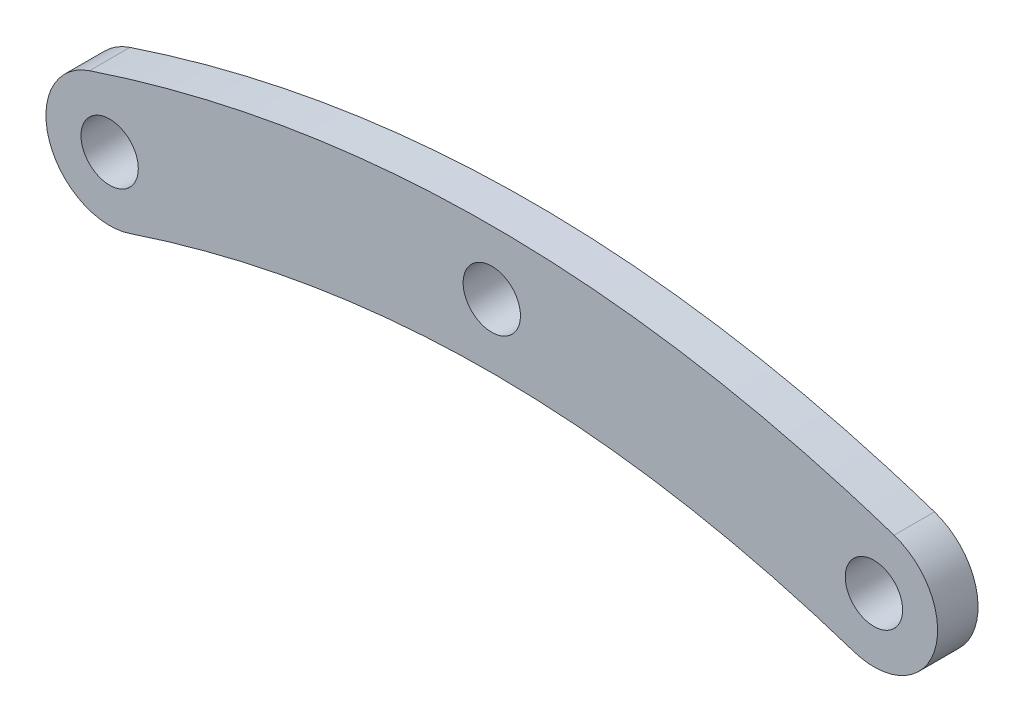
from build123d import *

# Parameters (mm, degrees)
BOSS_EXTRUDE1_DEPTH  = 1.5875
M4_CLEARANCE_HOLE1_D = 4.5


with BuildPart() as part:
    # Sketch1 → Boss-Extrude1 (new body, symmetric)
    with BuildSketch(Plane.XY):
        with BuildLine():
            ThreePointArc((-28.41886117, -9.74341649), (-34.74341649, -6.58113883), (-31.58113883, -0.25658351))
            add(Edge.make_bspline(
                [(-31.58113883, -0.25658351), (-19.788717071, 3.678862016), (0, 5.330284496), (19.788717071, 3.678862016), (31.58113883, -0.25658351)],
                knots=[0, 0, 0, 0.375, 0.625, 1, 1, 1], degree=2))
            ThreePointArc((31.58113883, -0.25658351), (34.74341649, -6.58113883), (28.41886117, -9.74341649))
            add(Edge.make_bspline(
                [(-28.41886117, -9.74341649), (-17.711282929, -6.178862016), (0, -4.705284496), (17.711282929, -6.178862016), (28.41886117, -9.74341649)],
                knots=[0, 0, 0, 0.375, 0.625, 1, 1, 1], degree=2))
        make_face()
    extrude(amount=BOSS_EXTRUDE1_DEPTH, both=True)

    # M4 Clearance Hole1 (through all)
    with Locations(Plane.XY.offset(1.5875)):
        with Locations((-30, -5), (30, -5), (0, 0)):
            Hole(M4_CLEARANCE_HOLE1_D / 2)


solid = part.part
